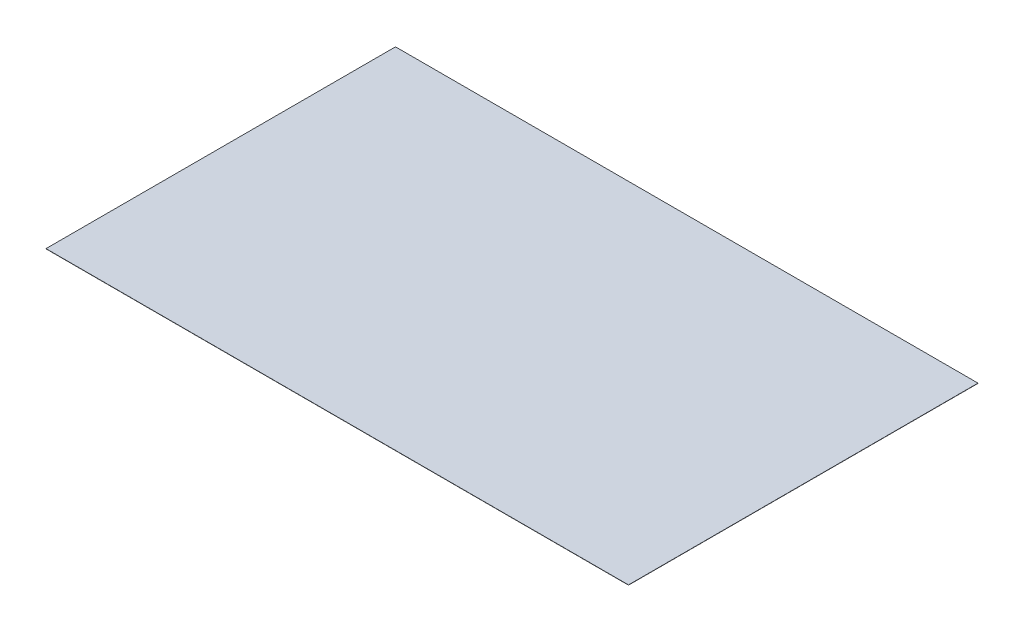
from build123d import *

# Parameters (mm, degrees)
SKETCH1_W           = 25
SKETCH1_H           = 15
BOSS_EXTRUDE1_DEPTH = 0.01


with BuildPart() as part:
    # Sketch1 → Boss-Extrude1 (new body)
    with BuildSketch(Plane(origin=(0, 0, 0), x_dir=(1, 0, 0), z_dir=(0, 1, 0))):
        with Locations((12.5, 7.5)):
            Rectangle(SKETCH1_W, SKETCH1_H)
    extrude(amount=BOSS_EXTRUDE1_DEPTH)


solid = part.part
